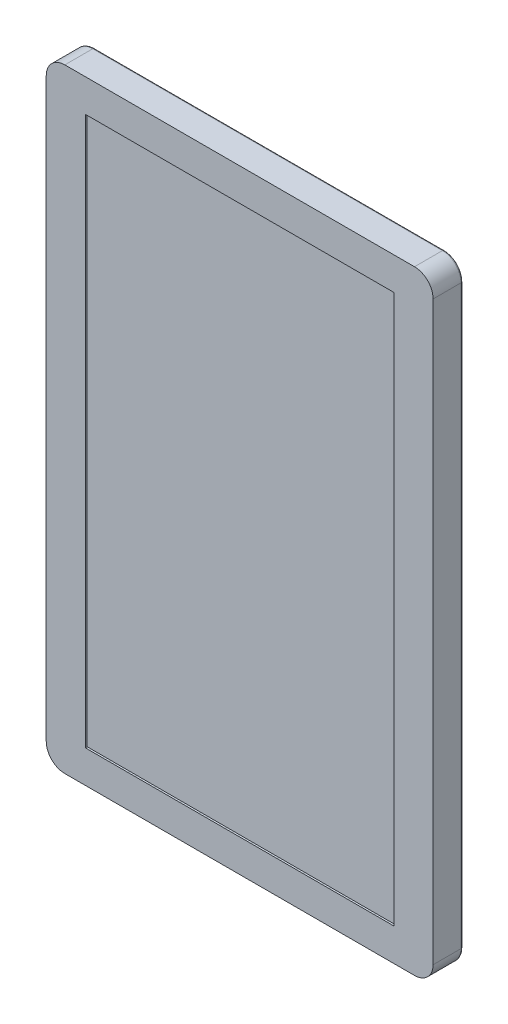
from build123d import *

# Parameters (mm, degrees)
BOSS_EXTRUDE1_DEPTH = 16
FILLET2_R           = 1
SKETCH2_W           = 166
SKETCH2_H           = 295
CUT_EXTRUDE1_DEPTH  = 1
SKETCH3_R           = 2.5
CUT_EXTRUDE2_DEPTH  = 10


with BuildPart() as part:
    # Sketch1 → Boss-Extrude1 (new body)
    with BuildSketch(Plane.XY):
        with BuildLine():
            Line((-94, 165), (94, 165))
            ThreePointArc((94, 165), (101.071067812, 162.071067812), (104, 155))
            Line((104, 155), (104, -155))
            ThreePointArc((104, -155), (101.071067812, -162.071067812), (94, -165))
            Line((94, -165), (-94, -165))
            ThreePointArc((-94, -165), (-101.071067812, -162.071067812), (-104, -155))
            Line((-104, -155), (-104, 155))
            ThreePointArc((-104, 155), (-101.071067812, 162.071067812), (-94, 165))
        make_face()
    extrude(amount=BOSS_EXTRUDE1_DEPTH)

    # Fillet2
    fillet2_edges = [part.edges().sort_by_distance(p)[0] for p in [
        (0, 165, 0),
        (101.071067812, 162.071067812, 0),
        (104, 0, 0),
        (101.071067812, -162.071067812, 0),
        (0, -165, 0),
        (-101.071067812, -162.071067812, 0),
        (-104, 0, 0),
        (-101.071067812, 162.071067812, 0),
    ]]
    fillet(fillet2_edges, radius=FILLET2_R)

    # Sketch2 → Cut-Extrude1 (cut)
    with BuildSketch(Plane.XY.offset(16)):
        Rectangle(SKETCH2_W, SKETCH2_H)
    extrude(amount=-CUT_EXTRUDE1_DEPTH, mode=Mode.SUBTRACT)

    # Sketch3 → Cut-Extrude2 (cut)
    with BuildSketch(Plane(origin=(0, 0, 0), x_dir=(-1, 0, 0), z_dir=(0, 0, -1))):
        with Locations((-50, 50)):
            Circle(SKETCH3_R)
        with Locations((50, 50)):
            Circle(SKETCH3_R)
        with Locations((50, -50)):
            Circle(SKETCH3_R)
        with Locations((-50, -50)):
            Circle(SKETCH3_R)
    extrude(amount=-CUT_EXTRUDE2_DEPTH, mode=Mode.SUBTRACT)


solid = part.part
